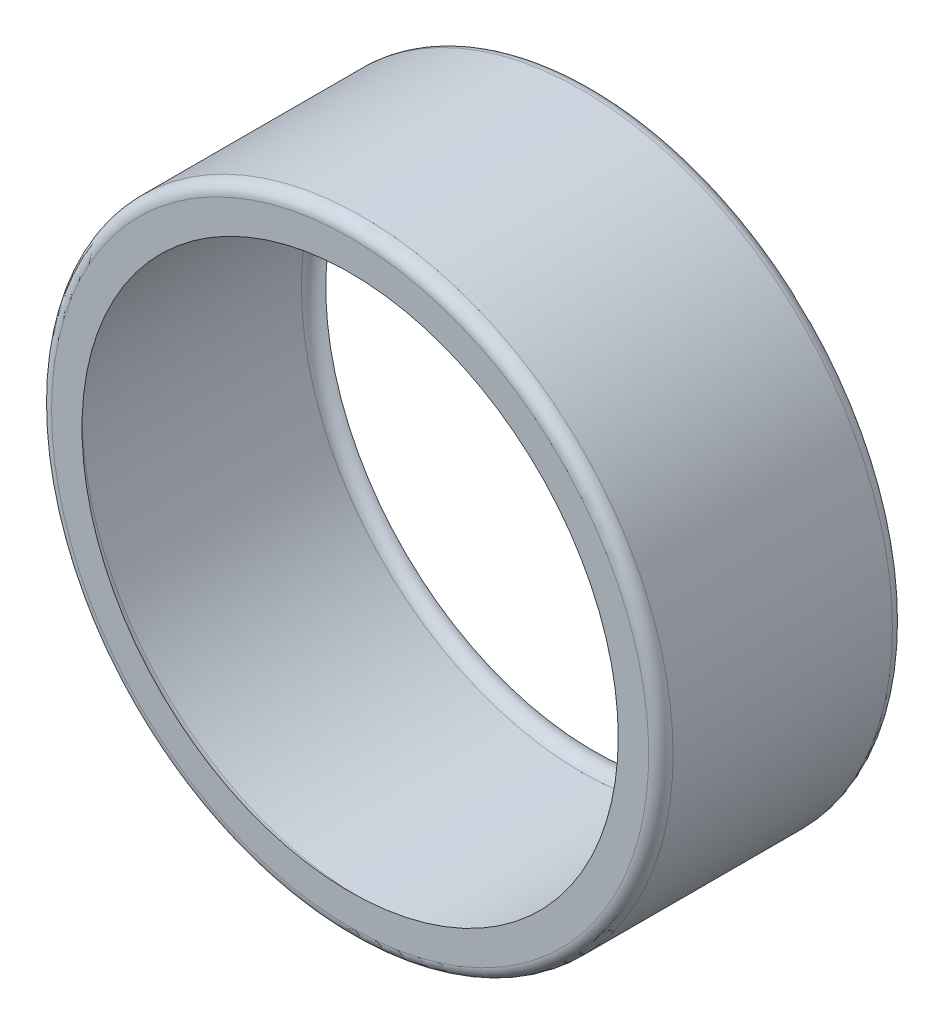
from build123d import *

# Parameters (mm, degrees)
FILLET1_R = 1.27


with BuildPart() as part:
    # Sketch1 → Revolve1 (revolve)
    with BuildSketch(Plane(origin=(0, 0, 0), x_dir=(0, 0, -1), z_dir=(1, 0, 0))):
        with BuildLine():
            Line((0, 27.94), (0, 32.385))
            Line((0, 32.385), (25.4, 32.385))
            Line((25.4, 32.385), (25.4, 27.94))
            ThreePointArc((25.4, 27.94), (25.028025612, 28.838025612), (24.13, 29.21))
            Line((24.13, 29.21), (1.27, 29.21))
            ThreePointArc((1.27, 29.21), (0.371974388, 28.838025612), (0, 27.94))
        make_face()
    revolve(axis=Axis((0, 0, 0), (0, 0, -1)))

    # Fillet1
    fillet1_edges = [part.edges().sort_by_distance(p)[0] for p in [
        (0, -32.385, -25.4),
        (0, -32.385, 0),
    ]]
    fillet(fillet1_edges, radius=FILLET1_R)


solid = part.part
